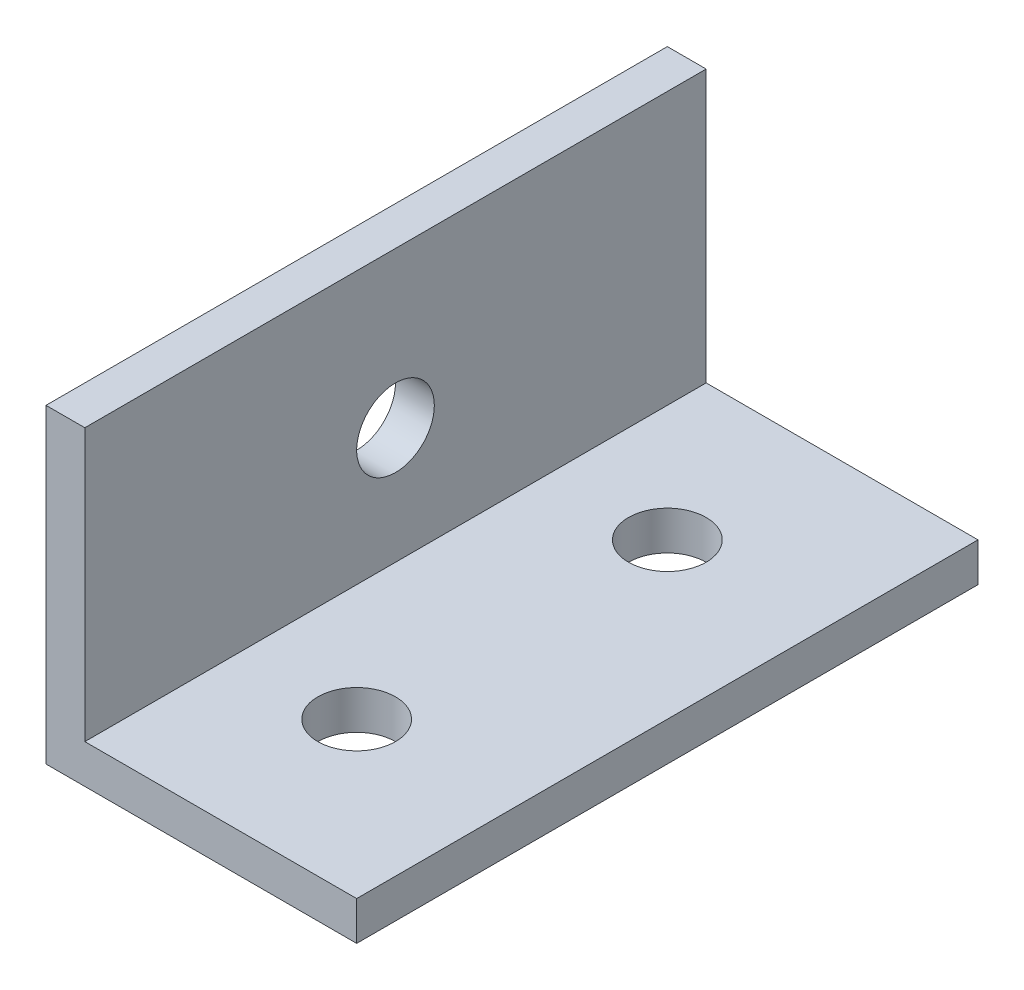
from build123d import *

# Parameters (mm, degrees)
BOSS_EXTRUDE1_DEPTH = 50.8
SKETCH2_R           = 3.175
CUT_EXTRUDE1_DEPTH  = 4.175
SKETCH3_R           = 3.175
CUT_EXTRUDE2_DEPTH  = 4.175


with BuildPart() as part:
    # Sketch1 → Boss-Extrude1 (new body)
    with BuildSketch(Plane.XY):
        Polygon((0, 0), (25.4, 0), (25.4, 3.175), (3.175, 3.175), (3.175, 25.4), (0, 25.4), align=None)
    extrude(amount=BOSS_EXTRUDE1_DEPTH)

    # Sketch2 → Cut-Extrude1 (cut, through all)
    with BuildSketch(Plane(origin=(3.175, 0, 0), x_dir=(0, 0, -1), z_dir=(1, 0, 0))):
        with Locations((-25.4, 12.7)):
            Circle(SKETCH2_R)
    extrude(amount=-CUT_EXTRUDE1_DEPTH, mode=Mode.SUBTRACT)

    # Sketch3 → Cut-Extrude2 (cut, through all)
    with BuildSketch(Plane(origin=(0, 3.175, 0), x_dir=(1, 0, 0), z_dir=(0, 1, 0))):
        with Locations((12.7, -38.1)):
            Circle(SKETCH3_R)
        with Locations((12.7, -12.7)):
            Circle(SKETCH3_R)
    extrude(amount=-CUT_EXTRUDE2_DEPTH, mode=Mode.SUBTRACT)


solid = part.part
